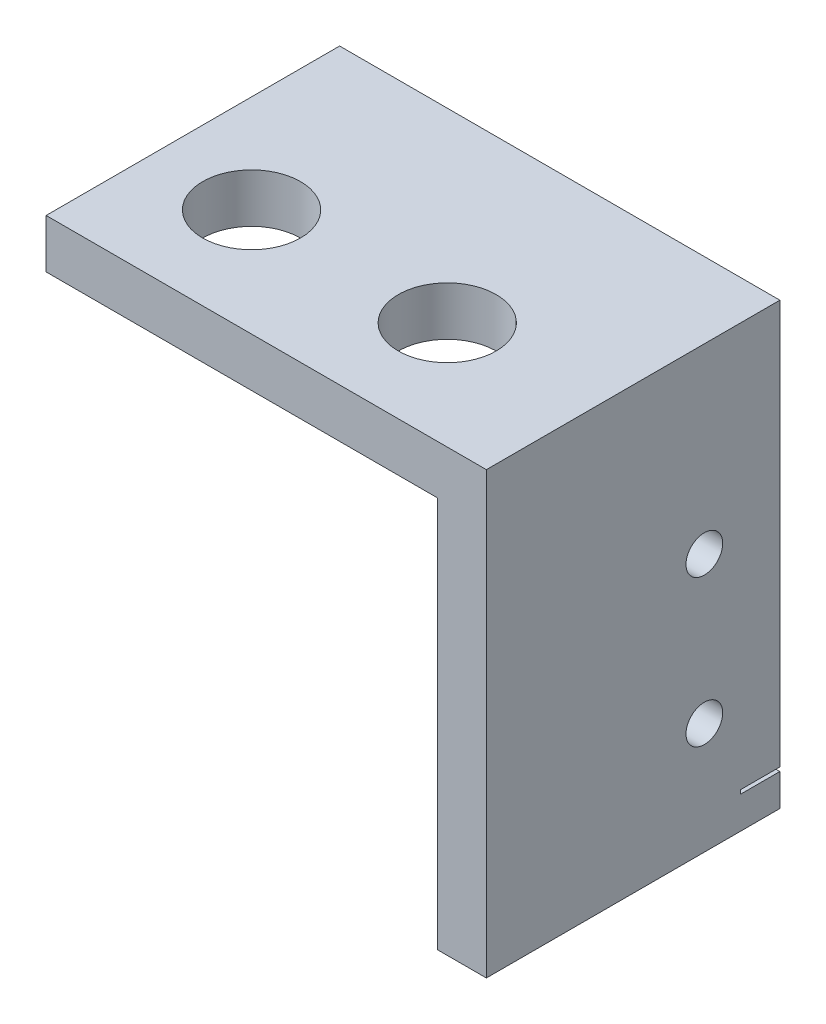
from build123d import *

# Parameters (mm, degrees)
SKETCH1_W           = 28.575
SKETCH1_H           = 3.175
SKETCH1_W_2         = 3.175
SKETCH1_H_2         = 25.4
BOSS_EXTRUDE1_DEPTH = 19.05
SWITCH_MOUNT_REACH  = 5.175
SKETCH2_R           = 1.190625
SKETCH2_W           = 2.54
SKETCH2_H           = 0.254
BRACKET_MOUNT_REACH = 5.175
SKETCH3_R           = 3.175


with BuildPart() as part:
    # Sketch1 → Boss-Extrude1 (new body)
    with BuildSketch(Plane.XY):
        with Locations((-14.2875, 1.5875)):
            Rectangle(SKETCH1_W, SKETCH1_H)
        with Locations((-1.5875, -12.7)):
            Rectangle(SKETCH1_W_2, SKETCH1_H_2)
    extrude(amount=BOSS_EXTRUDE1_DEPTH)

    # Sketch2 → Switch Mount (cut, up to next)
    with BuildSketch(Plane.ZY.offset(3.175), mode=Mode.PRIVATE) as switch_mount_sk1:
        with Locations((4.9022, -8.636)):
            Circle(SKETCH2_R)
    switch_mount_tool1 = extrude(switch_mount_sk1.sketch, amount=-SWITCH_MOUNT_REACH, mode=Mode.PRIVATE) & part.part
    add(switch_mount_tool1.solids().sort_by_distance((-3.175, -8.636, 4.9022))[0], mode=Mode.SUBTRACT)
    # Sketch2 → Switch Mount (cut, up to next)
    with BuildSketch(Plane.ZY.offset(3.175), mode=Mode.PRIVATE) as switch_mount_sk2:
        with Locations((4.9022, -18.161)):
            Circle(SKETCH2_R)
    switch_mount_tool2 = extrude(switch_mount_sk2.sketch, amount=-SWITCH_MOUNT_REACH, mode=Mode.PRIVATE) & part.part
    add(switch_mount_tool2.solids().sort_by_distance((-3.175, -18.161, 4.9022))[0], mode=Mode.SUBTRACT)
    # Sketch2 → Switch Mount (cut, up to next)
    with BuildSketch(Plane.ZY.offset(3.175), mode=Mode.PRIVATE) as switch_mount_sk3:
        with Locations((1.27, -23.1902)):
            Rectangle(SKETCH2_W, SKETCH2_H)
    switch_mount_tool3 = extrude(switch_mount_sk3.sketch, amount=-SWITCH_MOUNT_REACH, mode=Mode.PRIVATE) & part.part
    add(switch_mount_tool3.solids().sort_by_distance((-3.175, -23.1902, 1.27))[0], mode=Mode.SUBTRACT)

    # Sketch3 → Bracket Mount (cut, up to next)
    with BuildSketch(Plane.XZ, mode=Mode.PRIVATE) as bracket_mount_sk1:
        with Locations((-9.525, 12.065)):
            Circle(SKETCH3_R)
    bracket_mount_tool1 = extrude(bracket_mount_sk1.sketch, amount=-BRACKET_MOUNT_REACH, mode=Mode.PRIVATE) & part.part
    add(bracket_mount_tool1.solids().sort_by_distance((-9.525, 0, 12.065))[0], mode=Mode.SUBTRACT)
    # Sketch3 → Bracket Mount (cut, up to next)
    with BuildSketch(Plane.XZ, mode=Mode.PRIVATE) as bracket_mount_sk2:
        with Locations((-22.225, 12.065)):
            Circle(SKETCH3_R)
    bracket_mount_tool2 = extrude(bracket_mount_sk2.sketch, amount=-BRACKET_MOUNT_REACH, mode=Mode.PRIVATE) & part.part
    add(bracket_mount_tool2.solids().sort_by_distance((-22.225, 0, 12.065))[0], mode=Mode.SUBTRACT)


solid = part.part
